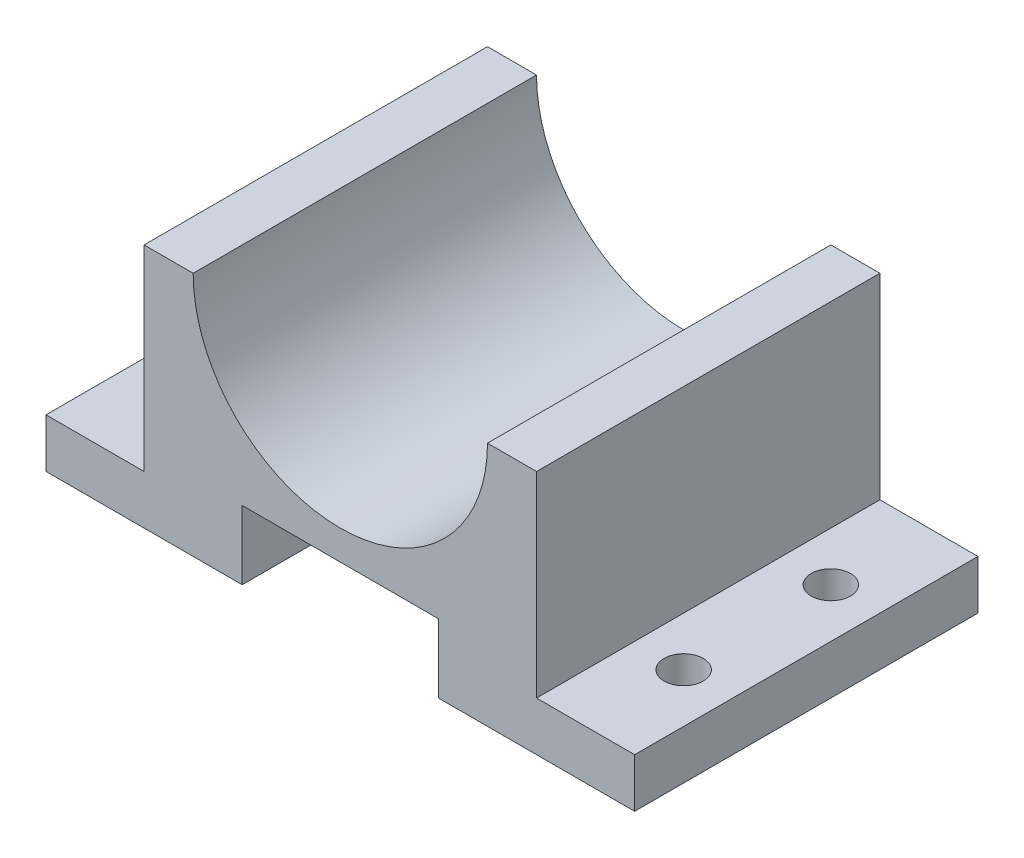
from build123d import *

# Parameters (mm, degrees)
IZIM1_W                     = 60
IZIM1_H                     = 25
Y_KSEKLIK_EKSTR_ZYON1_DEPTH = 35
IZIM2_W                     = 10
IZIM2_H                     = 20
IZIM2_W_2                   = 20
IZIM2_H_2                   = 7
KES_EKSTR_ZYON2_DEPTH       = 36
IZIM3_R                     = 2
KES_EKSTR_ZYON3_DEPTH       = 6


with BuildPart() as part:
    # Çizim1 → Yükseklik-Ekstrüzyon1 (new body)
    with BuildSketch(Plane.XY):
        with Locations((30, 12.5)):
            Rectangle(IZIM1_W, IZIM1_H)
    extrude(amount=Y_KSEKLIK_EKSTR_ZYON1_DEPTH)

    # Çizim2 → Kes-Ekstrüzyon2 (cut, through all)
    with BuildSketch(Plane.XY.offset(35)):
        with Locations((55, 15)):
            Rectangle(IZIM2_W, IZIM2_H)
        with BuildLine():
            Line((45, 25), (15, 25))
            ThreePointArc((15, 25), (30, 10), (45, 25))
        make_face()
        with Locations((5, 15)):
            Rectangle(IZIM2_W, IZIM2_H)
        with Locations((30, 3.5)):
            Rectangle(IZIM2_W_2, IZIM2_H_2)
    extrude(amount=-KES_EKSTR_ZYON2_DEPTH, mode=Mode.SUBTRACT)

    # Çizim3 → Kes-Ekstrüzyon3 (cut, through all)
    with BuildSketch(Plane(origin=(0, 5, 0), x_dir=(1, 0, 0), z_dir=(0, 1, 0))):
        with Locations((5, -25)):
            Circle(IZIM3_R)
        with Locations((5, -10)):
            Circle(IZIM3_R)
        with Locations((55, -10)):
            Circle(IZIM3_R)
        with Locations((55, -25)):
            Circle(IZIM3_R)
    extrude(amount=-KES_EKSTR_ZYON3_DEPTH, mode=Mode.SUBTRACT)


solid = part.part
